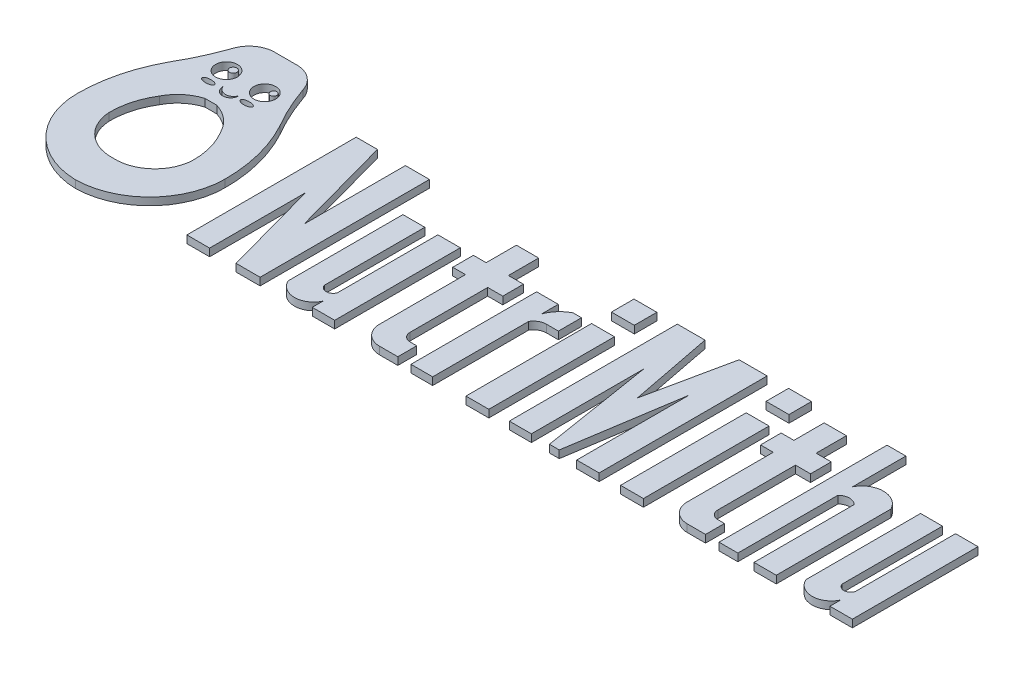
from build123d import *

# Parameters (mm, degrees)
BOSS_EXTRUDE1_DEPTH    = 0.3
BOSS_EXTRUDE1_2_DEPTH  = 0.3
BOSS_EXTRUDE1_3_DEPTH  = 0.3
BOSS_EXTRUDE1_4_DEPTH  = 0.3
BOSS_EXTRUDE1_5_DEPTH  = 0.3
SKETCH4_W              = 0.907139685
SKETCH4_H              = 4.980142663
BOSS_EXTRUDE1_6_DEPTH  = 0.3
SKETCH4_H_2            = 0.893475319
BOSS_EXTRUDE1_7_DEPTH  = 0.3
BOSS_EXTRUDE1_8_DEPTH  = 0.3
BOSS_EXTRUDE1_9_DEPTH  = 0.3
BOSS_EXTRUDE1_10_DEPTH = 0.3
BOSS_EXTRUDE1_11_DEPTH = 0.3
BOSS_EXTRUDE1_12_DEPTH = 0.3
SKETCH4_6_R            = 0.147132828
BOSS_EXTRUDE2_DEPTH    = 0.3
SKETCH4_6_R_2          = 0.128746351
BOSS_EXTRUDE2_2_DEPTH  = 0.3
SKETCH4_6_R_3          = 0.432552287
SKETCH4_6_RX           = 0.245064734
SKETCH4_6_RY           = 0.105973939
BOSS_EXTRUDE2_3_DEPTH  = 0.3


with BuildPart() as part:
    # Sketch4 → Boss-Extrude1 (new body)
    with BuildSketch(Plane(origin=(0, 0, 0), x_dir=(1, 0, 0), z_dir=(0, 1, 0))):
        Polygon((13.716879182, 18.278788665), (13.716879182, 24.991425443), (14.559248335, 24.991425443), (15.667628801, 20.968795109), (15.667628801, 24.991425443), (16.620836001, 24.991425443), (16.620836001, 18.278788665), (15.667628801, 18.278788665), (14.618732293, 22.08553467), (14.618732293, 18.278788665), align=None)
    extrude(amount=BOSS_EXTRUDE1_DEPTH)


with BuildPart() as body_2:
    # Sketch4 → Boss-Extrude1 2 (new body)
    with BuildSketch(Plane(origin=(0, 0, 0), x_dir=(1, 0, 0), z_dir=(0, 1, 0))):
        with BuildLine():
            Line((17.30087467, 23.258931328), (17.30087467, 18.710151468))
            ThreePointArc((17.30087467, 18.710151468), (17.992644328, 18.264567096), (18.687742823, 18.704940544))
            Line((18.687742823, 18.704940544), (18.687742823, 18.278788665))
            Line((18.687742823, 18.278788665), (19.577615355, 18.278788665))
            Line((19.577615355, 18.278788665), (19.577615355, 23.258931328))
            Line((19.577615355, 23.258931328), (18.687742823, 23.258931328))
            Line((18.687742823, 23.258931328), (18.687742823, 19.279390612))
            ThreePointArc((18.687742823, 19.279390612), (18.428784342, 19.091594892), (18.16982586, 19.279390612))
            Line((18.16982586, 19.279390612), (18.16982586, 23.258931328))
            Line((18.16982586, 23.258931328), (17.30087467, 23.258931328))
        make_face()
    extrude(amount=BOSS_EXTRUDE1_2_DEPTH)


with BuildPart() as body_3:
    # Sketch4 → Boss-Extrude1 3 (new body)
    with BuildSketch(Plane(origin=(0, 0, 0), x_dir=(1, 0, 0), z_dir=(0, 1, 0))):
        with BuildLine():
            Line((37.822440447, 23.258931328), (37.822440447, 18.710151468))
            ThreePointArc((37.822440447, 18.710151468), (38.514210105, 18.264567096), (39.209308601, 18.704940544))
            Line((39.209308601, 18.704940544), (39.209308601, 18.278788665))
            Line((39.209308601, 18.278788665), (40.099181132, 18.278788665))
            Line((40.099181132, 18.278788665), (40.099181132, 23.258931328))
            Line((40.099181132, 23.258931328), (39.209308601, 23.258931328))
            Line((39.209308601, 23.258931328), (39.209308601, 19.279390612))
            ThreePointArc((39.209308601, 19.279390612), (38.950350119, 19.091594892), (38.691391637, 19.279390612))
            Line((38.691391637, 19.279390612), (38.691391637, 23.258931328))
            Line((38.691391637, 23.258931328), (37.822440447, 23.258931328))
        make_face()
    extrude(amount=BOSS_EXTRUDE1_3_DEPTH)


with BuildPart() as body_4:
    # Sketch4 → Boss-Extrude1 4 (new body)
    with BuildSketch(Plane(origin=(0, 0, 0), x_dir=(1, 0, 0), z_dir=(0, 1, 0))):
        with BuildLine():
            Line((21.482574077, 19.364036479), (21.482574077, 22.439333993))
            Line((21.482574077, 22.439333993), (22.079282394, 22.439333993))
            Line((22.079282394, 22.439333993), (22.079282394, 23.258931328))
            Line((22.079282394, 23.258931328), (21.482574077, 23.258931328))
            Line((21.482574077, 23.258931328), (21.482574077, 24.458962143))
            Line((21.482574077, 24.458962143), (20.601281794, 24.458962143))
            Line((20.601281794, 24.458962143), (20.601281794, 23.258931328))
            Line((20.601281794, 23.258931328), (20.096374756, 23.258931328))
            Line((20.096374756, 23.258931328), (20.096374756, 22.439333993))
            Line((20.096374756, 22.439333993), (20.601281794, 22.439333993))
            Line((20.601281794, 22.439333993), (20.601281794, 19.028803404))
            ThreePointArc((20.601281794, 19.028803404), (20.820956025, 18.498462896), (21.351296532, 18.278788665))
            Line((21.351296532, 18.278788665), (22.079282394, 18.278788665))
            Line((22.079282394, 18.278788665), (22.079282394, 19.028803404))
            Line((22.079282394, 19.028803404), (21.817807152, 19.028803404))
            ThreePointArc((21.817807152, 19.028803404), (21.580761571, 19.126990898), (21.482574077, 19.364036479))
        make_face()
    extrude(amount=BOSS_EXTRUDE1_4_DEPTH)


with BuildPart() as body_5:
    # Sketch4 → Boss-Extrude1 5 (new body)
    with BuildSketch(Plane(origin=(0, 0, 0), x_dir=(1, 0, 0), z_dir=(0, 1, 0))):
        with BuildLine():
            Line((23.460734175, 22.600690426), (23.460734175, 23.258931328))
            Line((23.460734175, 23.258931328), (22.600423707, 23.258931328))
            Line((22.600423707, 23.258931328), (22.600423707, 18.278788665))
            Line((22.600423707, 18.278788665), (23.460734175, 18.278788665))
            Line((23.460734175, 18.278788665), (23.460734175, 22.08553467))
            ThreePointArc((23.460734175, 22.08553467), (23.651964482, 22.273390501), (23.911100107, 22.342002244))
            Line((23.911100107, 22.342002244), (24.381658901, 22.342002244))
            Line((24.381658901, 22.342002244), (24.381658901, 23.258931328))
            Line((24.381658901, 23.258931328), (24.047039314, 23.258931328))
            ThreePointArc((24.047039314, 23.258931328), (23.692752783, 22.984263823), (23.460734175, 22.600690426))
        make_face()
    extrude(amount=BOSS_EXTRUDE1_5_DEPTH)


with BuildPart() as body_6:
    # Sketch4 → Boss-Extrude1 6 (new body)
    with BuildSketch(Plane(origin=(0, 0, 0), x_dir=(1, 0, 0), z_dir=(0, 1, 0))):
        with Locations((25.233709616, 20.768859997)):
            Rectangle(SKETCH4_W, SKETCH4_H)
    extrude(amount=BOSS_EXTRUDE1_6_DEPTH)


with BuildPart() as body_7:
    # Sketch4 → Boss-Extrude1 7 (new body)
    with BuildSketch(Plane(origin=(0, 0, 0), x_dir=(1, 0, 0), z_dir=(0, 1, 0))):
        with Locations((25.233709616, 24.49285274)):
            Rectangle(SKETCH4_W, SKETCH4_H_2)
    extrude(amount=BOSS_EXTRUDE1_7_DEPTH)


with BuildPart() as body_8:
    # Sketch4 → Boss-Extrude1 8 (new body)
    with BuildSketch(Plane(origin=(0, 0, 0), x_dir=(1, 0, 0), z_dir=(0, 1, 0))):
        Polygon((26.49920087, 18.278788665), (26.49920087, 24.939590399), (27.597204595, 24.939590399), (28.244448896, 21.609189532), (28.949482866, 24.939590399), (30.059044525, 24.939590399), (30.059044525, 18.278788665), (29.172637859, 18.278788665), (29.172637859, 22.734019126), (28.47914926, 18.278788665), (28.088740973, 18.278788665), (27.37412163, 22.734019126), (27.37412163, 18.278788665), align=None)
    extrude(amount=BOSS_EXTRUDE1_8_DEPTH)


with BuildPart() as body_9:
    # Sketch4 → Boss-Extrude1 9 (new body)
    with BuildSketch(Plane(origin=(0, 0, 0), x_dir=(1, 0, 0), z_dir=(0, 1, 0))):
        with BuildLine():
            Line((34.812485031, 24.939590399), (35.559303143, 24.939590399))
            Line((35.559303143, 24.939590399), (35.559303143, 22.824753136))
            ThreePointArc((35.559303143, 22.824753136), (36.320550869, 23.290755349), (37.081798595, 22.824753136))
            Line((37.081798595, 22.824753136), (37.081798595, 18.278788665))
            Line((37.081798595, 18.278788665), (36.200381016, 18.278788665))
            Line((36.200381016, 18.278788665), (36.200381016, 22.246216016))
            ThreePointArc((36.200381016, 22.246216016), (35.87984208, 22.378987591), (35.559303143, 22.246216016))
            Line((35.559303143, 22.246216016), (35.559303143, 18.278788665))
            Line((35.559303143, 18.278788665), (34.812485031, 18.278788665))
            Line((34.812485031, 18.278788665), (34.812485031, 24.939590399))
        make_face()
    extrude(amount=BOSS_EXTRUDE1_9_DEPTH)


with BuildPart() as body_10:
    # Sketch4 → Boss-Extrude1 10 (new body)
    with BuildSketch(Plane(origin=(0, 0, 0), x_dir=(1, 0, 0), z_dir=(0, 1, 0))):
        with Locations((31.36312338, 24.49285274)):
            Rectangle(SKETCH4_W, SKETCH4_H_2)
    extrude(amount=BOSS_EXTRUDE1_10_DEPTH)


with BuildPart() as body_11:
    # Sketch4 → Boss-Extrude1 11 (new body)
    with BuildSketch(Plane(origin=(0, 0, 0), x_dir=(1, 0, 0), z_dir=(0, 1, 0))):
        with Locations((31.36312338, 20.768859997)):
            Rectangle(SKETCH4_W, SKETCH4_H)
    extrude(amount=BOSS_EXTRUDE1_11_DEPTH)


with BuildPart() as body_12:
    # Sketch4 → Boss-Extrude1 12 (new body)
    with BuildSketch(Plane(origin=(0, 0, 0), x_dir=(1, 0, 0), z_dir=(0, 1, 0))):
        with BuildLine():
            Line((32.801281794, 23.258931328), (32.296374756, 23.258931328))
            Line((32.296374756, 23.258931328), (32.296374756, 22.439333993))
            Line((32.296374756, 22.439333993), (32.801281794, 22.439333993))
            Line((32.801281794, 22.439333993), (32.801281794, 19.028803404))
            ThreePointArc((32.801281794, 19.028803404), (33.020956025, 18.498462896), (33.551296532, 18.278788665))
            Line((33.551296532, 18.278788665), (34.279282394, 18.278788665))
            Line((34.279282394, 18.278788665), (34.279282394, 19.028803404))
            Line((34.279282394, 19.028803404), (34.017807152, 19.028803404))
            ThreePointArc((34.017807152, 19.028803404), (33.780761571, 19.126990898), (33.682574077, 19.364036479))
            Line((33.682574077, 19.364036479), (33.682574077, 22.439333993))
            Line((33.682574077, 22.439333993), (34.279282394, 22.439333993))
            Line((34.279282394, 22.439333993), (34.279282394, 23.258931328))
            Line((34.279282394, 23.258931328), (33.682574077, 23.258931328))
            Line((33.682574077, 23.258931328), (33.682574077, 24.458962143))
            Line((33.682574077, 24.458962143), (32.801281794, 24.458962143))
            Line((32.801281794, 24.458962143), (32.801281794, 23.258931328))
        make_face()
    extrude(amount=BOSS_EXTRUDE1_12_DEPTH)


with BuildPart() as body_13:
    # Sketch4_6 → Boss-Extrude2 (new body)
    with BuildSketch(Plane(origin=(0, 0, 0), x_dir=(1, 0, 0), z_dir=(0, 1, 0))):
        with Locations((8.981326725, 24.853101935)):
            Circle(SKETCH4_6_R)
    extrude(amount=BOSS_EXTRUDE2_DEPTH)


with BuildPart() as body_14:
    # Sketch4_6 → Boss-Extrude2 2 (new body)
    with BuildSketch(Plane(origin=(0, 0, 0), x_dir=(1, 0, 0), z_dir=(0, 1, 0))):
        with Locations((10.58386497, 24.853101935)):
            Circle(SKETCH4_6_R_2)
    extrude(amount=BOSS_EXTRUDE2_2_DEPTH)


with BuildPart() as body_15:
    # Sketch4_6 → Boss-Extrude2 3 (new body)
    with BuildSketch(Plane(origin=(0, 0, 0), x_dir=(1, 0, 0), z_dir=(0, 1, 0))):
        with BuildLine():
            Line((9.108171814, 26.292778247), (10.136960985, 26.292778247))
            ThreePointArc((10.136960985, 26.292778247), (10.700721386, 26.064086351), (11.037739466, 25.557584045))
            ThreePointArc((11.037739466, 25.557584045), (11.384182372, 24.69751888), (11.812673895, 23.875247764))
            ThreePointArc((11.812673895, 23.875247764), (12.370307343, 22.457879176), (12.556346989, 20.946165571))
            ThreePointArc((12.556346989, 20.946165571), (11.696696401, 18.857707801), (9.6225664, 17.96404135))
            ThreePointArc((9.6225664, 17.96404135), (7.548436398, 18.857707801), (6.68878581, 20.946165571))
            ThreePointArc((6.68878581, 20.946165571), (6.874825456, 22.457879176), (7.432458904, 23.875247764))
            ThreePointArc((7.432458904, 23.875247764), (7.860950427, 24.69751888), (8.207393333, 25.557584045))
            ThreePointArc((8.207393333, 25.557584045), (8.544411413, 26.064086351), (9.108171814, 26.292778247))
        make_face()
        with Locations((8.86310708, 24.703169162)):
            Circle(SKETCH4_6_R_3, mode=Mode.SUBTRACT)
        with Locations((10.382025719, 24.703169162)):
            Circle(SKETCH4_6_R_3, mode=Mode.SUBTRACT)
        with Locations((8.86310708, 23.981221703)):
            Ellipse(SKETCH4_6_RX, SKETCH4_6_RY, mode=Mode.SUBTRACT)
        with Locations(Location((10.382025719, 23.981221703), (0, 0, 180))):
            Ellipse(SKETCH4_6_RX, SKETCH4_6_RY, mode=Mode.SUBTRACT)
        with BuildLine():
            Line((9.387739323, 23.325325591), (9.857393476, 23.325325591))
            ThreePointArc((9.857393476, 23.325325591), (10.431567344, 23.013741731), (10.840795065, 22.504533714))
            ThreePointArc((10.840795065, 22.504533714), (11.169631295, 21.756520837), (11.274420962, 20.946165571))
            ThreePointArc((11.274420962, 20.946165571), (10.757600506, 19.857805401), (9.6225664, 19.453665794))
            ThreePointArc((9.6225664, 19.453665794), (8.487532294, 19.857805401), (7.970711837, 20.946165571))
            ThreePointArc((7.970711837, 20.946165571), (8.075501505, 21.756520837), (8.404337734, 22.504533714))
            ThreePointArc((8.404337734, 22.504533714), (8.813565456, 23.013741731), (9.387739323, 23.325325591))
        make_face(mode=Mode.SUBTRACT)
        with BuildLine():
            ThreePointArc((9.340815034, 24.087195642), (9.656991499, 23.86705486), (9.973167963, 24.087195642))
            ThreePointArc((9.973167963, 24.087195642), (9.656991499, 23.760023424), (9.340815034, 24.087195642))
        make_face(mode=Mode.SUBTRACT)
    extrude(amount=BOSS_EXTRUDE2_3_DEPTH)


solid = Compound([part.part, body_2.part, body_3.part, body_4.part, body_5.part, body_6.part, body_7.part, body_8.part, body_9.part, body_10.part, body_11.part, body_12.part, body_13.part, body_14.part, body_15.part])
